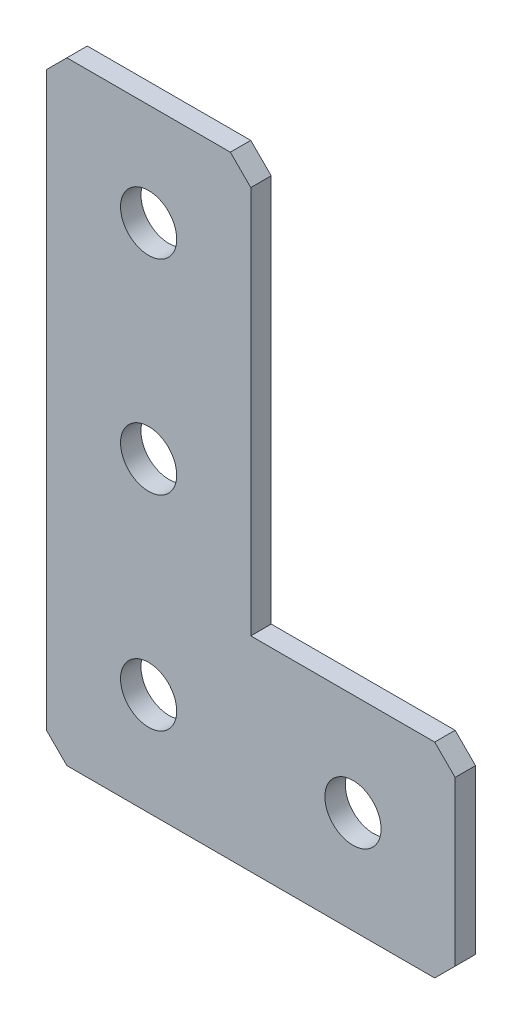
from build123d import *

# Parameters (mm, degrees)
EXTRUDE_1_DEPTH   = 2
HOLE_WIZARD_M51_D = 5.5
CHAMFER_1_SIZE    = 2


with BuildPart() as part:
    # Эскиз1 → Бобышка-Вытянуть1 (new body)
    with BuildSketch(Plane(origin=(0, 0, 0), x_dir=(1, 0, 0), z_dir=(0, 0, -1))):
        Polygon((0, 0), (0, 60), (40, 60), (40, 40), (20, 40), (20, 0), align=None)
    extrude(amount=EXTRUDE_1_DEPTH)

    # Отверстие с зазором M51 (through all)
    with Locations(Plane(origin=(0, 0, -2), x_dir=(1, 0, 0), z_dir=(0, 0, -1))):
        with Locations((30, 50), (10, 50), (10, 30), (10, 10)):
            Hole(HOLE_WIZARD_M51_D / 2)

    # Фаска1
    chamfer_1_edges = [part.edges().sort_by_distance(p)[0] for p in [
        (0, 0, -1),
        (0, -60, -1),
        (40, -60, -1),
        (40, -40, -1),
        (20, 0, -1),
    ]]
    chamfer(chamfer_1_edges, length=CHAMFER_1_SIZE)


solid = part.part
